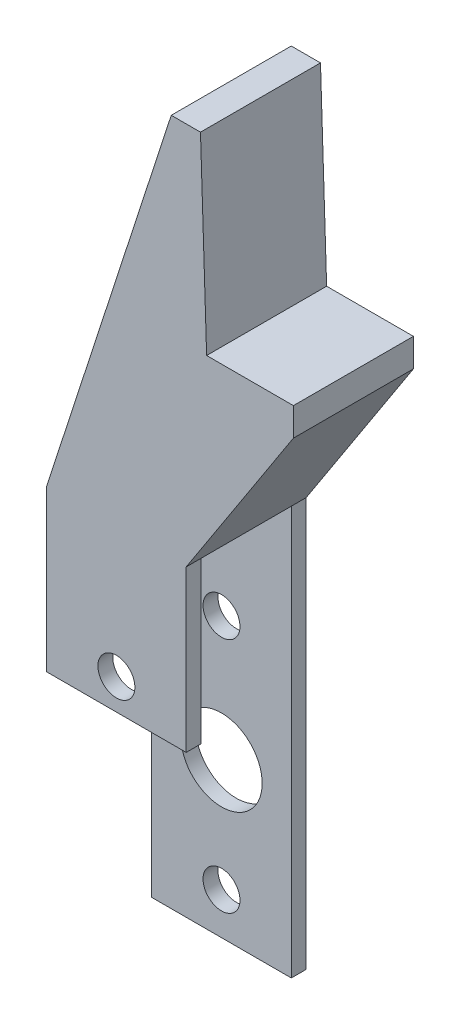
from build123d import *

# Parameters (mm, degrees)
BOSS_EXTRUDE3_DEPTH = 12.2936
CUT_EXTRUDE3_DEPTH  = 14.3002
SKETCH3_R           = 1.8923
SKETCH3_R_2         = 4.16814
CUT_EXTRUDE4_DEPTH  = 14.3002


with BuildPart() as part:
    # Sketch1 → Boss-Extrude3 (new body)
    with BuildSketch(Plane.XY):
        Polygon((-110.51464309, 1.262410177), (-96.21444309, 1.262410177), (-96.21444309, 43.121610177), (-85.230380887, 60.035582724), (-85.230380887, 62.924026373), (-94.120096356, 62.924026373), (-94.749967174, 82.424781559), (-97.744268584, 82.424781559), (-110.51464309, 43.121610177), align=None)
    extrude(amount=BOSS_EXTRUDE3_DEPTH)

    # Sketch2 → Cut-Extrude3 (cut)
    with BuildSketch(Plane(origin=(-96.21444309, 0, 0), x_dir=(0, 0, -1), z_dir=(1, 0, 0))):
        Polygon((-12.2936, 26.662410177), (-12.2936, 1.262410177), (-10.7696, 1.262410177), (-1.524, 1.262410177), (-1.524, 43.121610177), (-10.7696, 43.121610177), (-10.7696, 26.662410177), align=None)
    extrude(amount=-CUT_EXTRUDE3_DEPTH, mode=Mode.SUBTRACT)

    # Sketch3 → Cut-Extrude4 (cut)
    with BuildSketch(Plane(origin=(0, 0, 0), x_dir=(-1, 0, 0), z_dir=(0, 0, -1))):
        with Locations((103.36454309, 5.529610177)):
            Circle(SKETCH3_R)
        with Locations((103.36454309, 29.812010177)):
            Circle(SKETCH3_R)
        with Locations((103.36454309, 17.035810177)):
            Circle(SKETCH3_R_2)
    extrude(amount=-CUT_EXTRUDE4_DEPTH, mode=Mode.SUBTRACT)


solid = part.part
